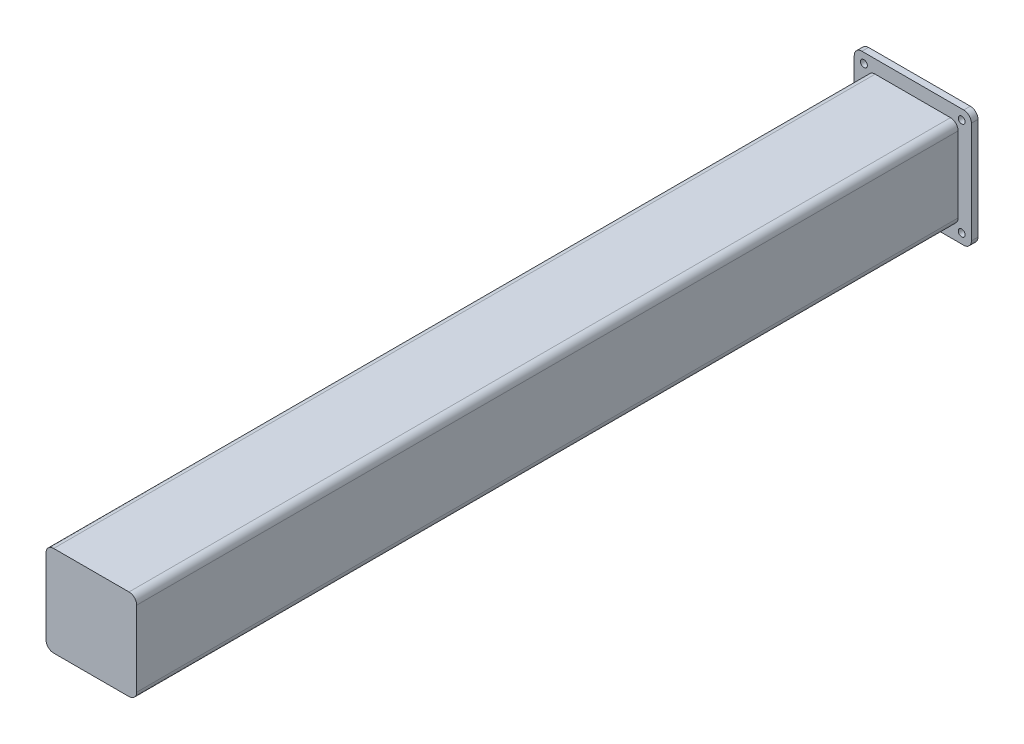
from build123d import *

# Parameters (mm, degrees)
SKETCH1_W           = 115
SKETCH1_H           = 115
BOSS_EXTRUDE1_DEPTH = 6.5
SKETCH2_W           = 89
SKETCH2_H           = 89
BOSS_EXTRUDE2_DEPTH = 806.45
FILLET1_R           = 7.5
SKETCH3_R           = 3.3782
CUT_EXTRUDE1_DEPTH  = 6.5
SHELL1_T            = -5


with BuildPart() as part:
    # Sketch1 → Boss-Extrude1 (new body)
    with BuildSketch(Plane.XY):
        Rectangle(SKETCH1_W, SKETCH1_H)
    extrude(amount=BOSS_EXTRUDE1_DEPTH)

    # Sketch2 → Boss-Extrude2 (add)
    with BuildSketch(Plane.XY.offset(6.5)):
        Rectangle(SKETCH2_W, SKETCH2_H)
    extrude(amount=BOSS_EXTRUDE2_DEPTH)

    # Fillet1
    fillet1_edges = [part.edges().sort_by_distance(p)[0] for p in [
        (44.5, -44.5, 409.725),
        (44.5, 44.5, 409.725),
        (-44.5, 44.5, 409.725),
        (-44.5, -44.5, 409.725),
        (57.5, -57.5, 3.25),
        (-57.5, -57.5, 3.25),
        (-57.5, 57.5, 3.25),
        (57.5, 57.5, 3.25),
    ]]
    fillet(fillet1_edges, radius=FILLET1_R)

    # Sketch3 → Cut-Extrude1 (cut)
    with BuildSketch(Plane.XY.offset(6.5)):
        with Locations((48, -48)):
            Circle(SKETCH3_R)
        with Locations((-48, 48)):
            Circle(SKETCH3_R)
        with Locations((48, 48)):
            Circle(SKETCH3_R)
        with Locations((-48, -48)):
            Circle(SKETCH3_R)
    extrude(amount=-CUT_EXTRUDE1_DEPTH, mode=Mode.SUBTRACT)

    # Shell1
    shell1_openings = [part.faces().sort_by_distance(p)[0] for p in [
        (-51.3782, -48, 0),
    ]]
    offset(amount=SHELL1_T, openings=shell1_openings, kind=Kind.INTERSECTION)


solid = part.part
